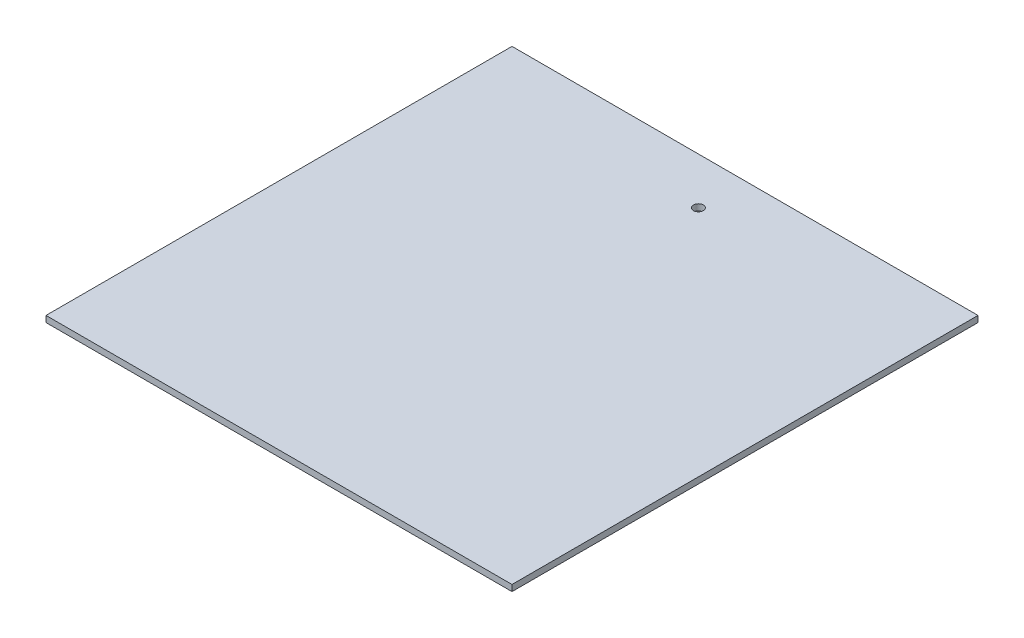
from build123d import *

# Parameters (mm, degrees)
SKETCH1_W           = 190.5
SKETCH1_H           = 190.5
BOSS_EXTRUDE1_DEPTH = 2.54
SKETCH2_R           = 2.032
CUT_EXTRUDE1_DEPTH  = 2.54


with BuildPart() as part:
    # Sketch1 → Boss-Extrude1 (new body)
    with BuildSketch(Plane(origin=(0, 0, 0), x_dir=(1, 0, 0), z_dir=(0, 1, 0))):
        Rectangle(SKETCH1_W, SKETCH1_H)
    extrude(amount=BOSS_EXTRUDE1_DEPTH)

    # Sketch2 → Cut-Extrude1 (cut)
    with BuildSketch(Plane(origin=(0, 2.54, 0), x_dir=(1, 0, 0), z_dir=(0, 1, 0))):
        with Locations((0.000813673, 76.199186327)):
            Circle(SKETCH2_R)
    extrude(amount=-CUT_EXTRUDE1_DEPTH, mode=Mode.SUBTRACT)


solid = part.part
